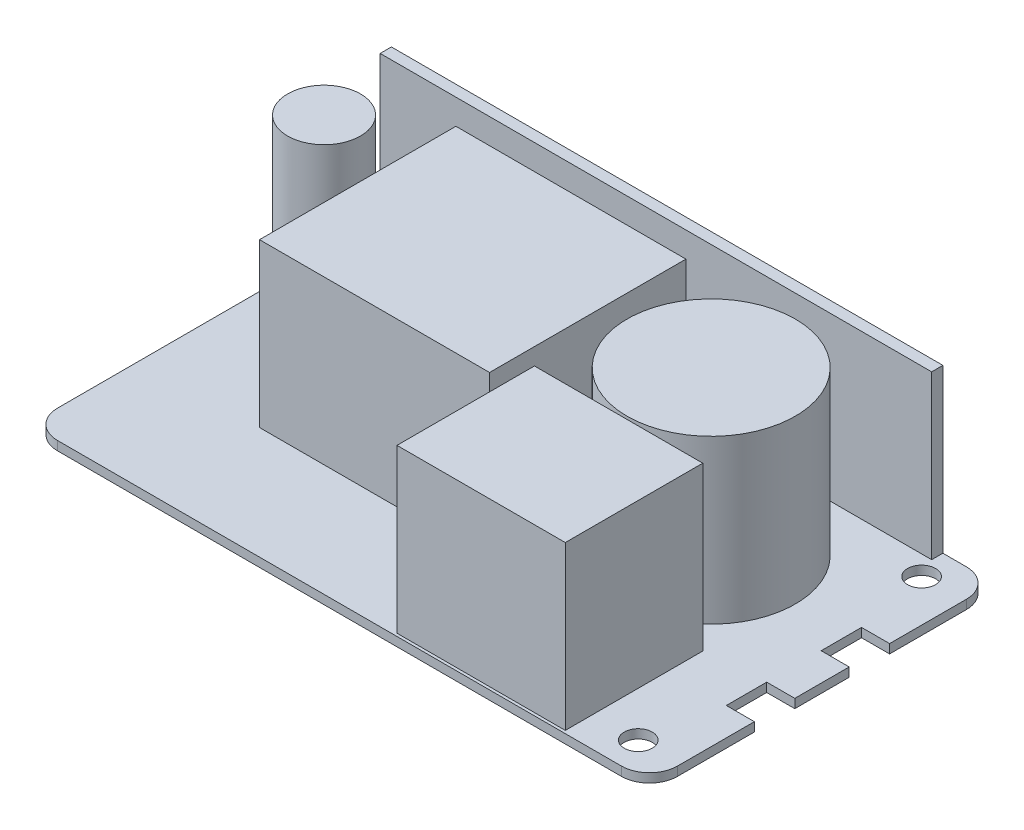
from build123d import *

# Parameters (mm, degrees)
EXTRUDE_1_DEPTH     = 1.6
SKETCH_2_R          = 2.5
CUT_EXTRUDE_1_DEPTH = 1.6
SKETCH_3_R          = 15
SKETCH_3_R_2        = 6.5
SKETCH_3_W          = 98.3
SKETCH_3_H          = 2
SKETCH_3_W_2        = 30
SKETCH_3_H_2        = 24.5
SKETCH_3_W_3        = 41
SKETCH_3_H_3        = 35
EXTRUDE_2_DEPTH     = 29


with BuildPart() as part:
    # 草图1 → 凸台-拉伸1 (new body)
    with BuildSketch(Plane(origin=(0, 0, 0), x_dir=(1, 0, 0), z_dir=(0, 1, 0))):
        with BuildLine():
            Line((55.25, 12.05), (50.25, 12.05))
            Line((50.25, 12.05), (50.25, 4.85))
            Line((50.25, 4.85), (55.25, 4.85))
            Line((55.25, 4.85), (55.25, -4.85))
            Line((55.25, -4.85), (50.25, -4.85))
            Line((50.25, -4.85), (50.25, -12.05))
            Line((50.25, -12.05), (55.25, -12.05))
            Line((55.25, -12.05), (55.25, -25.75))
            ThreePointArc((55.25, -25.75), (53.785533906, -29.285533906), (50.25, -30.75))
            Line((50.25, -30.75), (-50.25, -30.75))
            ThreePointArc((-50.25, -30.75), (-53.785533906, -29.285533906), (-55.25, -25.75))
            Line((-55.25, -25.75), (-55.25, 25.75))
            ThreePointArc((-55.25, 25.75), (-53.785533906, 29.285533906), (-50.25, 30.75))
            Line((-50.25, 30.75), (50.25, 30.75))
            ThreePointArc((50.25, 30.75), (53.785533906, 29.285533906), (55.25, 25.75))
            Line((55.25, 25.75), (55.25, 12.05))
        make_face()
    extrude(amount=EXTRUDE_1_DEPTH)

    # 草图2 → 切除-拉伸1 (cut)
    with BuildSketch(Plane(origin=(0, 1.6, 0), x_dir=(1, 0, 0), z_dir=(0, 1, 0))):
        with Locations((47.75, 25.25)):
            Circle(SKETCH_2_R)
        with Locations((47.75, -25.25)):
            Circle(SKETCH_2_R)
    extrude(amount=-CUT_EXTRUDE_1_DEPTH, mode=Mode.SUBTRACT)

    # 草图3 → 凸台-拉伸2 (add)
    with BuildSketch(Plane(origin=(0, 1.6, 0), x_dir=(1, 0, 0), z_dir=(0, 1, 0))):
        with Locations((25.75, 9.75)):
            Circle(SKETCH_3_R)
        with Locations((-47.75, 14.25)):
            Circle(SKETCH_3_R_2)
        with Locations((-3.1, 29.75)):
            Rectangle(SKETCH_3_W, SKETCH_3_H)
        with Locations((24.75, -18)):
            Rectangle(SKETCH_3_W_2, SKETCH_3_H_2)
        with Locations((-13.75, 6.75)):
            Rectangle(SKETCH_3_W_3, SKETCH_3_H_3)
    extrude(amount=EXTRUDE_2_DEPTH)


solid = part.part
